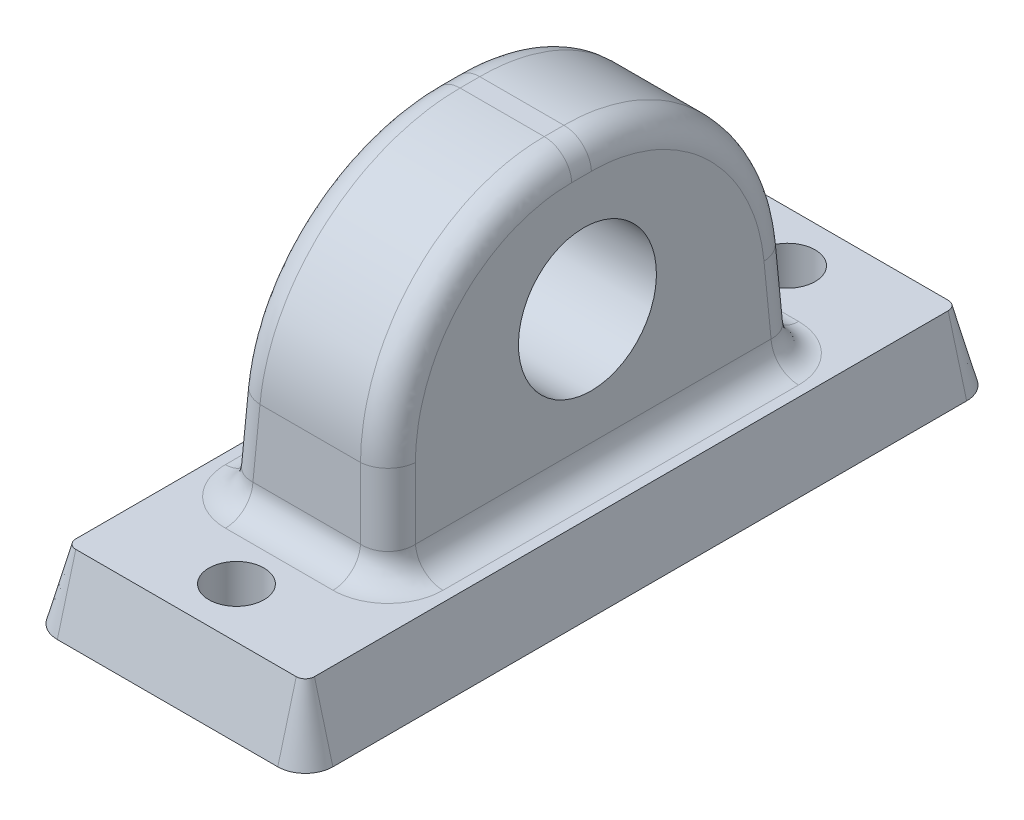
from build123d import *

# Parameters (mm, degrees)
BOSS_EXTRUDE1_DEPTH = 5
BOSS_EXTRUDE1_TAPER = 15
SKETCH2_R           = 2
CUT_EXTRUDE1_DEPTH  = 5
SKETCH3_W           = 12
SKETCH3_H           = 30
BOSS_EXTRUDE2_DEPTH = 20
BOSS_EXTRUDE2_TAPER = 3
FILLET1_R           = 13.95
FILLET2_R           = 2
SKETCH4_R           = 5
CUT_EXTRUDE2_DEPTH  = 24


with BuildPart() as part:
    # Sketch1 → Boss-Extrude1 (new body)
    with BuildSketch(Plane(origin=(0, 0, 0), x_dir=(1, 0, 0), z_dir=(0, 1, 0))):
        with BuildLine():
            Line((-8, -25), (8, -25))
            ThreePointArc((8, -25), (9.414213562, -24.414213562), (10, -23))
            Line((10, -23), (10, 23))
            ThreePointArc((10, 23), (9.414213562, 24.414213562), (8, 25))
            Line((8, 25), (-8, 25))
            ThreePointArc((-8, 25), (-9.414213562, 24.414213562), (-10, 23))
            Line((-10, 23), (-10, -23))
            ThreePointArc((-10, -23), (-9.414213562, -24.414213562), (-8, -25))
        make_face()
    extrude(amount=BOSS_EXTRUDE1_DEPTH, taper=BOSS_EXTRUDE1_TAPER)

    # Sketch2 → Cut-Extrude1 (cut)
    with BuildSketch(Plane(origin=(0, 5, 0), x_dir=(1, 0, 0), z_dir=(0, 1, 0))):
        with Locations((0, 20)):
            Circle(SKETCH2_R)
        with Locations((0, -20)):
            Circle(SKETCH2_R)
    extrude(amount=-CUT_EXTRUDE1_DEPTH, mode=Mode.SUBTRACT)

    # Sketch3 → Boss-Extrude2 (add)
    with BuildSketch(Plane(origin=(0, 5, 0), x_dir=(1, 0, 0), z_dir=(0, 1, 0))):
        Rectangle(SKETCH3_W, SKETCH3_H)
    extrude(amount=BOSS_EXTRUDE2_DEPTH, taper=BOSS_EXTRUDE2_TAPER)

    # Fillet1
    fillet1_edges = [part.edges().sort_by_distance(p)[0] for p in [
        (0, 25, -13.951844414),
        (0, 25, 13.951844414),
    ]]
    fillet(fillet1_edges, radius=FILLET1_R)

    # Fillet2
    fillet2_edges = [part.edges().sort_by_distance(p)[0] for p in [
        (6, 5, 0),
        (0, 5, -15),
        (-6, 5, 0),
        (0, 5, 15),
        (4.951844414, 25, 0),
        (-4.951844414, 25, 0),
        (-5.822335359, 8.390043295, 14.822335359),
        (-5.822335359, 8.390043295, -14.822335359),
        (-5.152783381, 21.165856107, 10.319617936),
        (-5.152783381, 21.165856107, -10.319617936),
        (5.822335359, 8.390043295, -14.822335359),
        (5.822335359, 8.390043295, 14.822335359),
        (5.152783381, 21.165856107, 10.319617936),
        (5.152783381, 21.165856107, -10.319617936),
    ]]
    fillet(fillet2_edges, radius=FILLET2_R)

    # Sketch4 → Cut-Extrude2 (cut)
    with BuildSketch(Plane(origin=(6, 0, 0), x_dir=(0, 0, -1), z_dir=(1, 0, 0))):
        with Locations((0, 15)):
            Circle(SKETCH4_R)
    extrude(amount=-CUT_EXTRUDE2_DEPTH, mode=Mode.SUBTRACT)


solid = part.part
